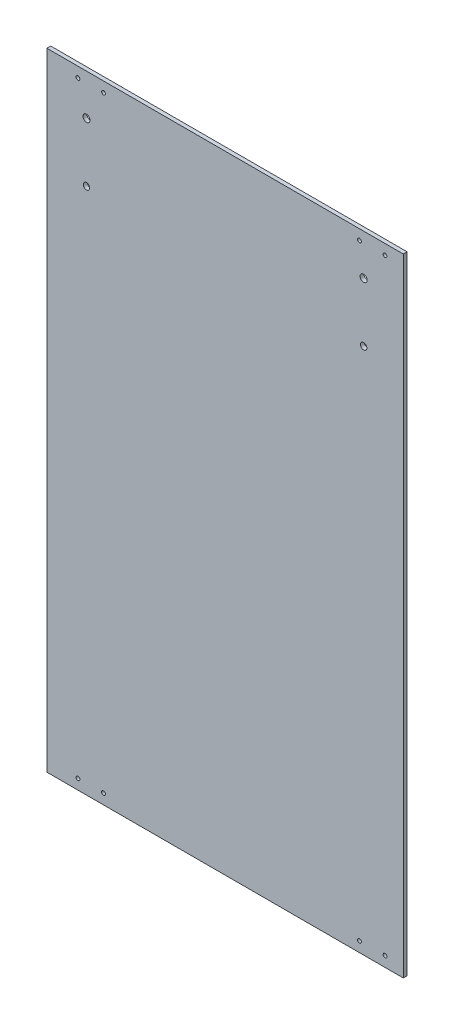
from build123d import *

# Parameters (mm, degrees)
SKETCH_1_W               = 278.56
SKETCH_1_H               = 490
SKETCH_1_R               = 1.5
EXTRUDE_1_DEPTH          = 3
SKETCH_2_R               = 2.5
CUT_EXTRUDE_1_DEPTH      = 10
SKETCH_3_R               = 2.75
CUT_EXTRUDE_2_DEPTH      = 1
CUT_EXTRUDE_2_DEPTH_BACK = 4


with BuildPart() as part:
    # 草图1 → 凸台-拉伸1 (new body)
    with BuildSketch(Plane.XY):
        Rectangle(SKETCH_1_W, SKETCH_1_H)
        with Locations((104.999070074, 237)):
            Circle(SKETCH_1_R, mode=Mode.SUBTRACT)
        with Locations((124.999070074, 237)):
            Circle(SKETCH_1_R, mode=Mode.SUBTRACT)
        with Locations((-95.000929926, 237)):
            Circle(SKETCH_1_R, mode=Mode.SUBTRACT)
        with Locations((-115.000929926, 237)):
            Circle(SKETCH_1_R, mode=Mode.SUBTRACT)
        with Locations((124.999070074, -237)):
            Circle(SKETCH_1_R, mode=Mode.SUBTRACT)
        with Locations((104.999070074, -237)):
            Circle(SKETCH_1_R, mode=Mode.SUBTRACT)
        with Locations((-95.000929926, -237)):
            Circle(SKETCH_1_R, mode=Mode.SUBTRACT)
        with Locations((-115.000929926, -237)):
            Circle(SKETCH_1_R, mode=Mode.SUBTRACT)
    extrude(amount=EXTRUDE_1_DEPTH)

    # 草图2 → 切除-拉伸1 (cut)
    with BuildSketch(Plane(origin=(0, 0, 0), x_dir=(-1, 0, 0), z_dir=(0, 0, -1))):
        with Locations((-108.275205997, 167.088125342)):
            Circle(SKETCH_2_R)
        with Locations((108.284794003, 167.088125342)):
            Circle(SKETCH_2_R)
    extrude(amount=-CUT_EXTRUDE_1_DEPTH, mode=Mode.SUBTRACT)

    # 草图3 → 切除-拉伸2 (cut, two sides)
    with BuildSketch(Plane(origin=(0, 0, 0), x_dir=(-1, 0, 0), z_dir=(0, 0, -1))) as cut_extrude_2_sk:
        with Locations((108.284794003, 213.088125342)):
            Circle(SKETCH_3_R)
        with Locations((-108.275205997, 213.088125342)):
            Circle(SKETCH_3_R)
    extrude(amount=CUT_EXTRUDE_2_DEPTH, mode=Mode.SUBTRACT)
    extrude(cut_extrude_2_sk.sketch, amount=-CUT_EXTRUDE_2_DEPTH_BACK, mode=Mode.SUBTRACT)


solid = part.part
